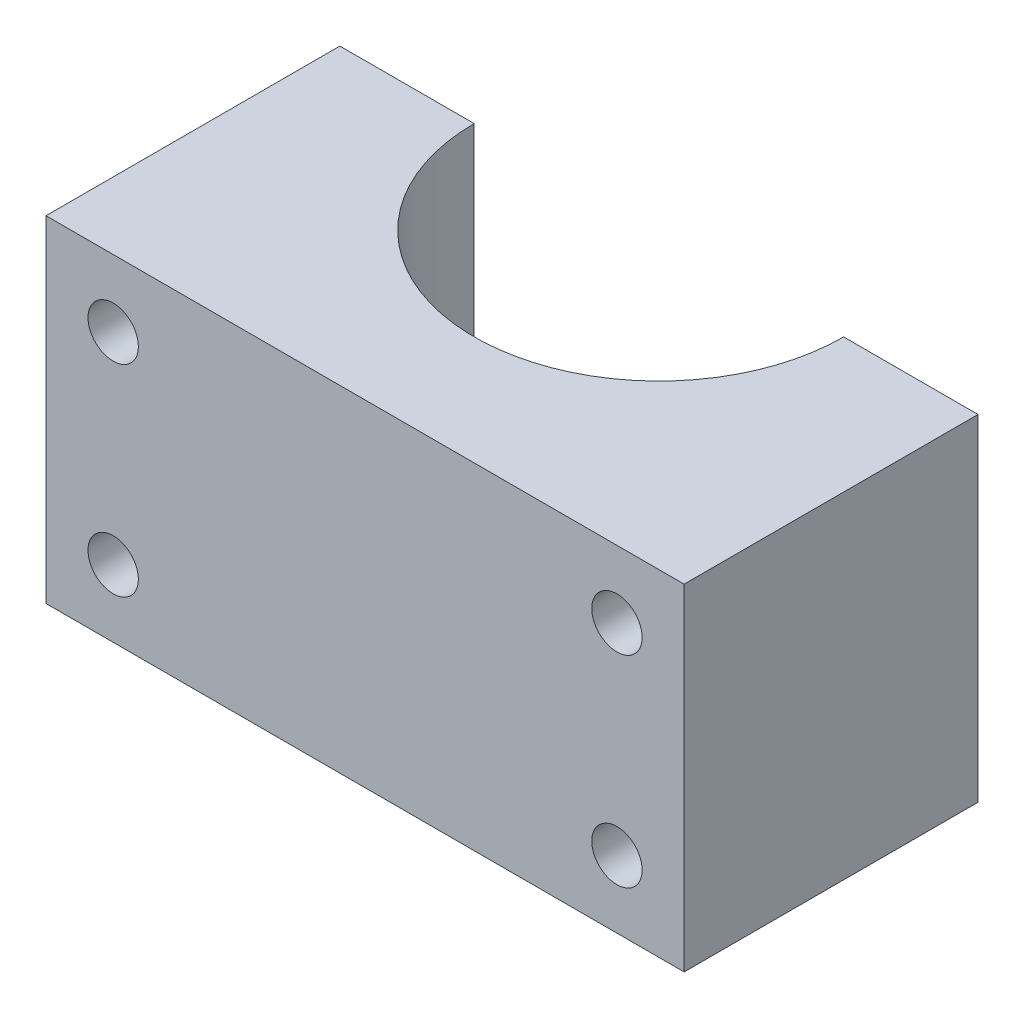
from build123d import *

# Parameters (mm, degrees)
SALIENTE_EXTRUIR1_DEPTH = 20
CROQUIS2_R              = 1.5
CORTAR_EXTRUIR1_DEPTH   = 18.5


with BuildPart() as part:
    # Croquis1 → Saliente-Extruir1 (new body)
    with BuildSketch(Plane(origin=(0, 0, 0), x_dir=(1, 0, 0), z_dir=(0, 1, 0))):
        with BuildLine():
            Line((-19, 0), (-11, 0))
            ThreePointArc((-11, 0), (0, -11), (11, 0))
            Line((11, 0), (19, 0))
            Line((19, 0), (19, -17.5))
            Line((19, -17.5), (-19, -17.5))
            Line((-19, -17.5), (-19, 0))
        make_face()
    extrude(amount=SALIENTE_EXTRUIR1_DEPTH)

    # Croquis2 → Cortar-Extruir1 (cut, through all)
    with BuildSketch(Plane.XY.offset(17.5)):
        with Locations((-15, 16)):
            Circle(CROQUIS2_R)
        with Locations((-15, 4)):
            Circle(CROQUIS2_R)
        with Locations((15, 4)):
            Circle(CROQUIS2_R)
        with Locations((15, 16)):
            Circle(CROQUIS2_R)
    extrude(amount=-CORTAR_EXTRUIR1_DEPTH, mode=Mode.SUBTRACT)


solid = part.part
